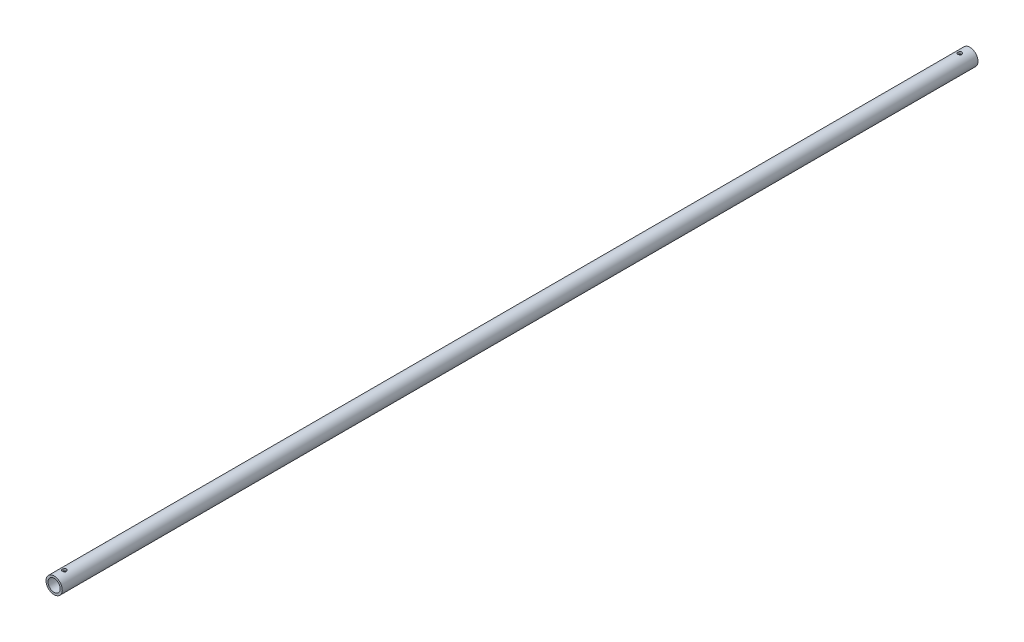
from build123d import *

# Parameters (mm, degrees)
EXTRUDE_1_DEPTH          = 225
EXTRUDE_1_DEPTH_BACK     = 225
SKETCH_1_R               = 4
SKETCH_1_R_2             = 3
CUT_EXTRUDE_2_DEPTH      = 226.071099877
CUT_EXTRUDE_2_DEPTH_BACK = 226.071099877
SKETCH_3_R               = 1


with BuildPart() as part:
    # 草图1 → 凸台-拉伸1 (new, two sides: drawn at the far end of the back side and taken through both)
    with BuildSketch(Plane.XY.offset(-EXTRUDE_1_DEPTH_BACK)):
        Circle(SKETCH_1_R)
        Circle(SKETCH_1_R_2, mode=Mode.SUBTRACT)
    extrude(amount=EXTRUDE_1_DEPTH + EXTRUDE_1_DEPTH_BACK)

    # 草图3 → 切除-拉伸2 (cut, two sides: drawn at the far end of the back side and taken through both)
    with BuildSketch(Plane(origin=(0, 0, 0), x_dir=(1, 0, 0), z_dir=(0, 1, 0)).offset(-CUT_EXTRUDE_2_DEPTH_BACK)):
        with Locations((0, 220)):
            Circle(SKETCH_3_R)
        with Locations((0, -220)):
            Circle(SKETCH_3_R)
    extrude(amount=CUT_EXTRUDE_2_DEPTH + CUT_EXTRUDE_2_DEPTH_BACK, mode=Mode.SUBTRACT)


solid = part.part
